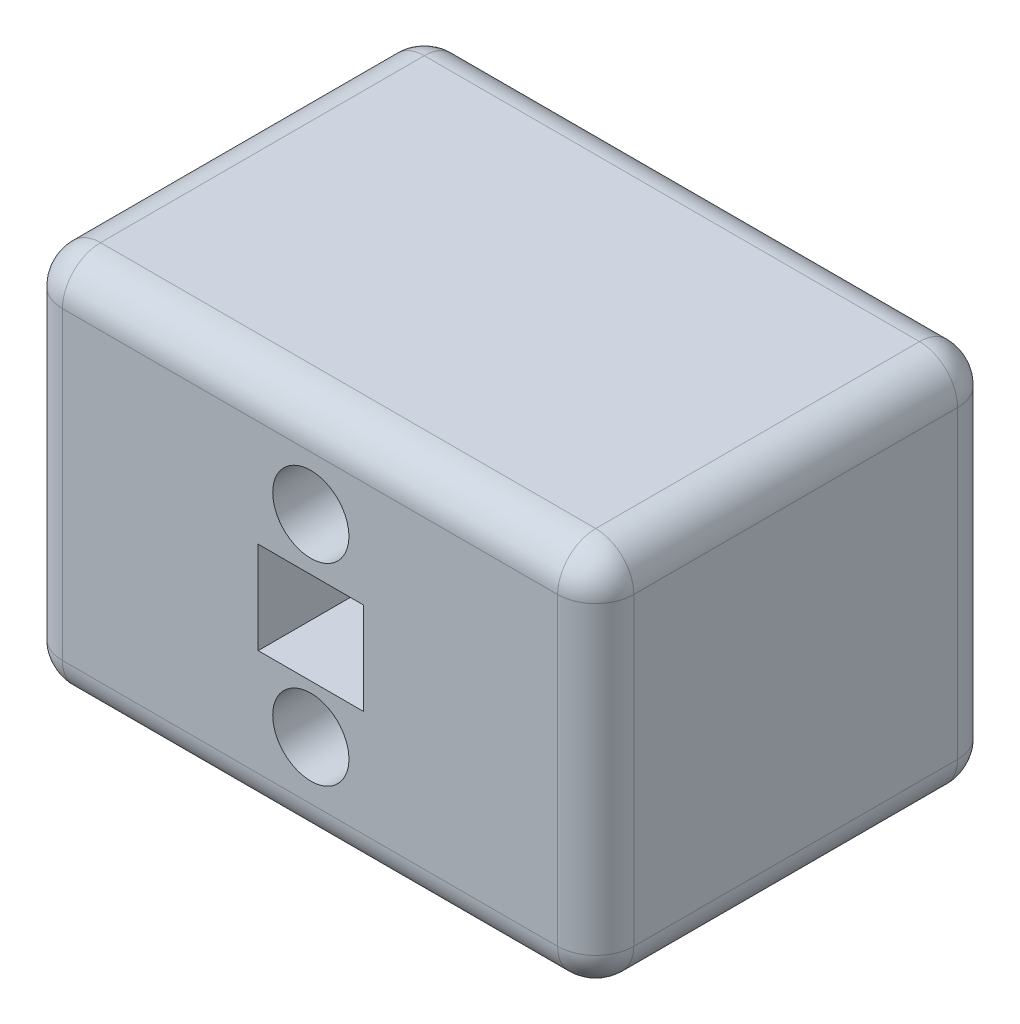
from build123d import *

# Parameters (mm, degrees)
SKETCH1_W                = 150
SKETCH1_H                = 100
BOSS_EXTRUDE1_DEPTH      = 60
BOSS_EXTRUDE1_DEPTH_BACK = 45
SKETCH5_W                = 27.629917719
SKETCH5_H                = 24.20295118
CUT_EXTRUDE1_DEPTH       = 79
CUT_EXTRUDE1_DEPTH_BACK  = 83
FILLET1_R                = 10
SKETCH7_R                = 10
CUT_EXTRUDE2_DEPTH       = 125


with BuildPart() as part:
    # Sketch1 → Boss-Extrude1 (new body, two sides)
    with BuildSketch(Plane.XY) as boss_extrude1_sk:
        with Locations((75, 50)):
            Rectangle(SKETCH1_W, SKETCH1_H)
    extrude(amount=BOSS_EXTRUDE1_DEPTH)
    extrude(boss_extrude1_sk.sketch, amount=-BOSS_EXTRUDE1_DEPTH_BACK)

    # Sketch5 → Cut-Extrude1 (cut, two sides)
    with BuildSketch(Plane(origin=(42.452521569, 36, 0), x_dir=(1, 0, 0), z_dir=(0, 0, 1))) as cut_extrude1_sk:
        with Locations((32.75337542, 14.030268891)):
            Rectangle(SKETCH5_W, SKETCH5_H)
    extrude(amount=CUT_EXTRUDE1_DEPTH, mode=Mode.SUBTRACT)
    extrude(cut_extrude1_sk.sketch, amount=-CUT_EXTRUDE1_DEPTH_BACK, mode=Mode.SUBTRACT)

    # Fillet1
    fillet1_edges = [part.edges().sort_by_distance(p)[0] for p in [
        (75, 0, -45),
        (0, 50, -45),
        (75, 100, -45),
        (150, 50, -45),
        (75, 100, 60),
        (0, 50, 60),
        (75, 0, 60),
        (0, 0, 7.5),
        (0, 100, 7.5),
        (150, 100, 7.5),
        (150, 0, 7.5),
        (150, 50, 60),
    ]]
    fillet(fillet1_edges, radius=FILLET1_R)

    # Sketch7 → Cut-Extrude2 (cut, symmetric)
    with BuildSketch(Plane.XY):
        with Locations((75.20589699, 75.819077446)):
            Circle(SKETCH7_R)
        with Locations((75.20589699, 25.173963995)):
            Circle(SKETCH7_R)
    extrude(amount=CUT_EXTRUDE2_DEPTH, both=True, mode=Mode.SUBTRACT)


solid = part.part
